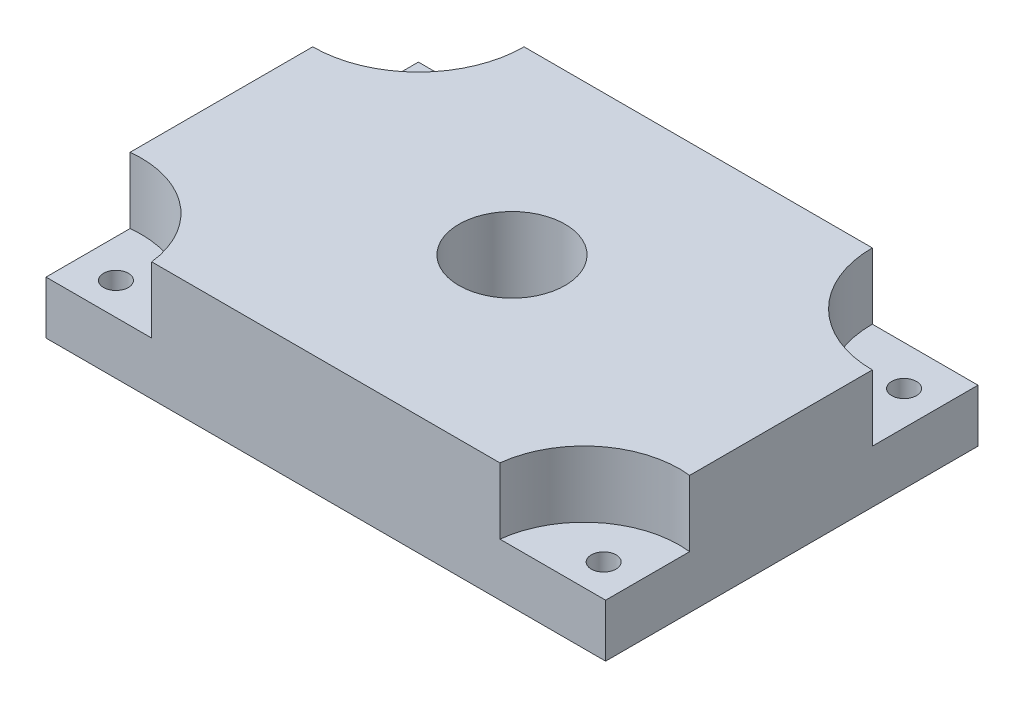
from build123d import *

# Parameters (mm, degrees)
SKETCH1_W                           = 26.9
SKETCH1_H                           = 17.9
BOSS_EXTRUDE1_DEPTH                 = 2.54
BOSS_EXTRUDE2_DEPTH                 = 3.175
F_1_4_20_TAPPED_HOLE1_D             = 5.1054
F_1_4_20_TAPPED_HOLE1_DEPTH         = 5.715
F_3_64_0_04688_DIAMETER_HOLE1_D     = 1.190752
F_3_64_0_04688_DIAMETER_HOLE1_DEPTH = 2.54


with BuildPart() as part:
    # Sketch1 → Boss-Extrude1 (new body)
    with BuildSketch(Plane(origin=(0, 0, 0), x_dir=(1, 0, 0), z_dir=(0, 1, 0))):
        Rectangle(SKETCH1_W, SKETCH1_H)
    extrude(amount=BOSS_EXTRUDE1_DEPTH)

    # Sketch2 → Boss-Extrude2 (add)
    with BuildSketch(Plane(origin=(0, 2.54, 0), x_dir=(1, 0, 0), z_dir=(0, 1, 0))):
        with BuildLine():
            Line((-8.37, -8.95), (8.37, -8.95))
            ThreePointArc((8.37, -8.95), (10.073421181, -5.878217622), (13.45, -4.910640141))
            Line((13.45, -4.910640141), (13.45, 3.87))
            ThreePointArc((13.45, 3.87), (9.857897552, 5.357897552), (8.37, 8.95))
            Line((8.37, 8.95), (-8.37, 8.95))
            ThreePointArc((-8.37, 8.95), (-9.857897552, 5.357897552), (-13.45, 3.87))
            Line((-13.45, 3.87), (-13.45, -4.910640141))
            ThreePointArc((-13.45, -4.910640141), (-10.073421181, -5.878217622), (-8.37, -8.95))
        make_face()
    extrude(amount=BOSS_EXTRUDE2_DEPTH)

    # 1/4-20 Tapped Hole1
    with Locations(Plane(origin=(0, 5.715, 0), x_dir=(1, 0, 0), z_dir=(0, 1, 0))):
        with Locations((0, 0)):
            Hole(F_1_4_20_TAPPED_HOLE1_D / 2, depth=F_1_4_20_TAPPED_HOLE1_DEPTH)

    # 3/64 (0.04688) Diameter Hole1
    with Locations(Plane(origin=(0, 2.54, 0), x_dir=(1, 0, 0), z_dir=(0, 1, 0))):
        with Locations((-11.630674377, 7.033069438), (-11.630674377, -7.406874263), (11.813402436, -7.406874263), (11.813402436, 7.033069438)):
            Hole(F_3_64_0_04688_DIAMETER_HOLE1_D / 2, depth=F_3_64_0_04688_DIAMETER_HOLE1_DEPTH)


solid = part.part
